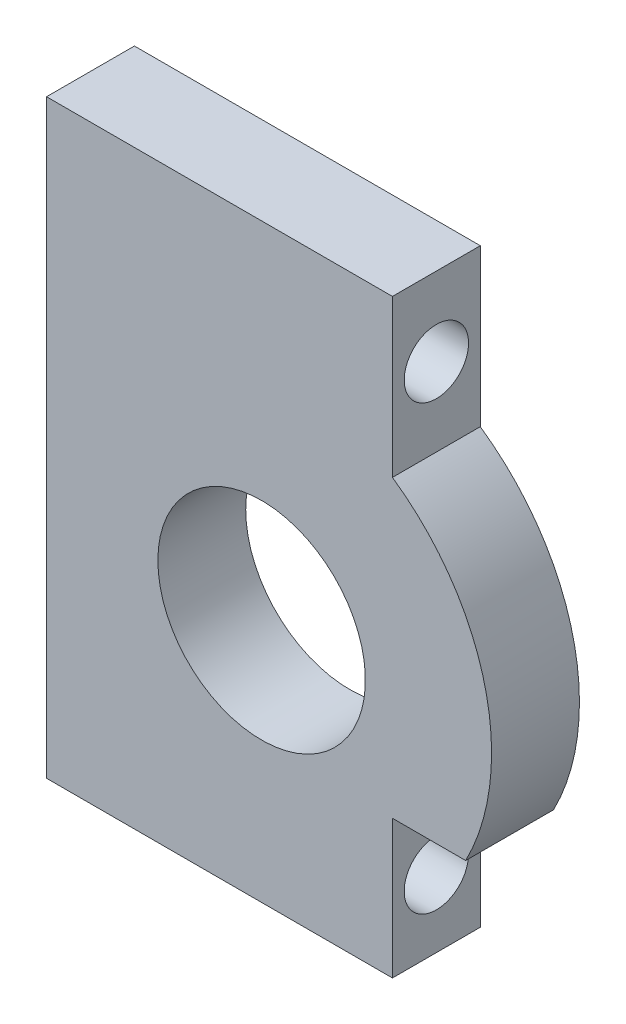
from build123d import *

# Parameters (mm, degrees)
BOSS_EXTRUDE1_DEPTH      = 3.175
BOSS_EXTRUDE1_DEPTH_BACK = 3.175
SKETCH2_R                = 7.5
CUT_EXTRUDE1_REACH       = 86.824
SKETCH3_R                = 2.325


with BuildPart() as part:
    # Sketch2 → Boss-Extrude1 (new, two sides: drawn at the far end of the back side and taken through both)
    with BuildSketch(Plane(origin=(0, 0, -13.2), x_dir=(-1, 0, 0), z_dir=(0, 0, -1)).offset(-BOSS_EXTRUDE1_DEPTH_BACK)):
        with BuildLine():
            Line((-19.1, 36.72), (-44.1, 36.72))
            Line((-44.1, 36.72), (-44.1, 46.72))
            Line((-44.1, 46.72), (-49.39334567, 46.72))
            ThreePointArc((-49.39334567, 46.72), (-50.77714312, 58.387484646), (-44.1, 68.055))
            Line((-44.1, 68.055), (-44.1, 79.385))
            Line((-44.1, 79.385), (-19.1, 79.385))
            Line((-19.1, 79.385), (-19.1, 36.72))
        make_face()
        with Locations((-34.645, 54.385)):
            Circle(SKETCH2_R, mode=Mode.SUBTRACT)
    extrude(amount=BOSS_EXTRUDE1_DEPTH + BOSS_EXTRUDE1_DEPTH_BACK)

    # Sketch3 → Cut-Extrude1 (cut, up to next)
    with BuildSketch(Plane(origin=(44.1, 0, 0), x_dir=(0, 0, -1), z_dir=(1, 0, 0)), mode=Mode.PRIVATE) as cut_extrude1_sk1:
        with Locations((13.2, 41.72)):
            Circle(SKETCH3_R)
    cut_extrude1_tool1 = extrude(cut_extrude1_sk1.sketch, amount=-CUT_EXTRUDE1_REACH, mode=Mode.PRIVATE) & part.part
    # Sketch3 → Cut-Extrude1 (cut, up to next)
    with BuildSketch(Plane(origin=(44.1, 0, 0), x_dir=(0, 0, -1), z_dir=(1, 0, 0)), mode=Mode.PRIVATE) as cut_extrude1_sk2:
        with Locations((13.2, 73.72)):
            Circle(SKETCH3_R)
    cut_extrude1_tool2 = extrude(cut_extrude1_sk2.sketch, amount=-CUT_EXTRUDE1_REACH, mode=Mode.PRIVATE) & part.part
    add(cut_extrude1_tool1.solids().sort_by_distance((44.1, 41.72, -13.2))[0], mode=Mode.SUBTRACT)
    add(cut_extrude1_tool2.solids().sort_by_distance((44.1, 73.72, -13.2))[0], mode=Mode.SUBTRACT)


solid = part.part
